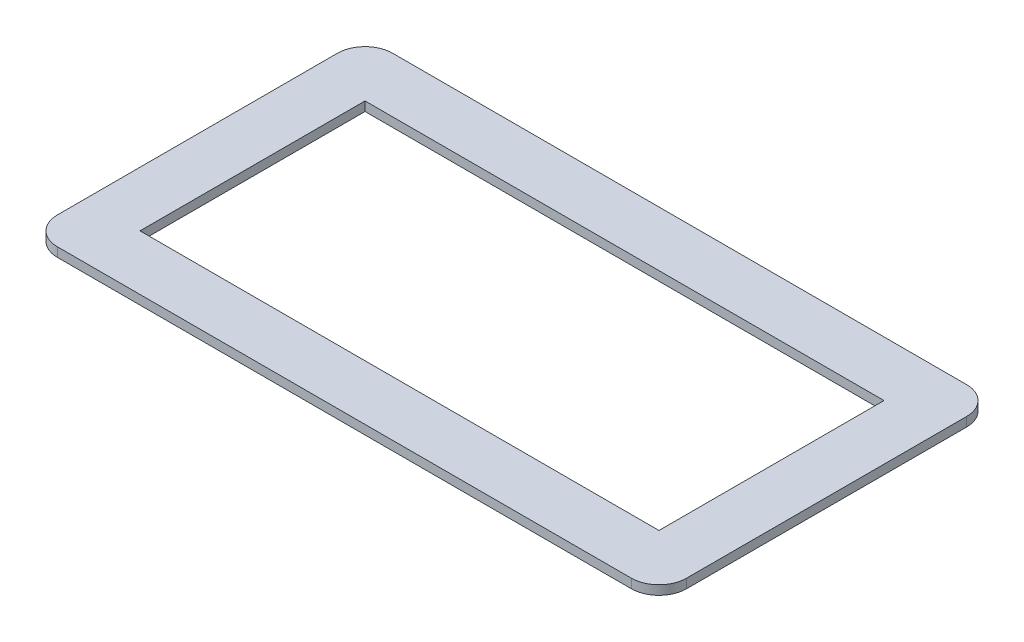
from build123d import *

# Parameters (mm, degrees)
SKETCH_1_W      = 68.5
SKETCH_1_H      = 36.5
SKETCH_1_W_2    = 56.5
SKETCH_1_H_2    = 24.5
EXTRUDE_1_DEPTH = 1
FILLET_1_R      = 3


with BuildPart() as part:
    # 草图1 → 凸台-拉伸1 (new body)
    with BuildSketch(Plane(origin=(0, 0, 0), x_dir=(1, 0, 0), z_dir=(0, 1, 0))):
        with Locations((-124.87745098, 48.691176471)):
            Rectangle(SKETCH_1_W, SKETCH_1_H)
        with Locations((-124.87745098, 48.691176471)):
            Rectangle(SKETCH_1_W_2, SKETCH_1_H_2, mode=Mode.SUBTRACT)
    extrude(amount=EXTRUDE_1_DEPTH)

    # 圆角1
    fillet_1_edges = [part.edges().sort_by_distance(p)[0] for p in [
        (-159.12745098, 0.5, -66.941176471),
        (-90.62745098, 0.5, -66.941176471),
        (-90.62745098, 0.5, -30.441176471),
        (-159.12745098, 0.5, -30.441176471),
    ]]
    fillet(fillet_1_edges, radius=FILLET_1_R)


solid = part.part
